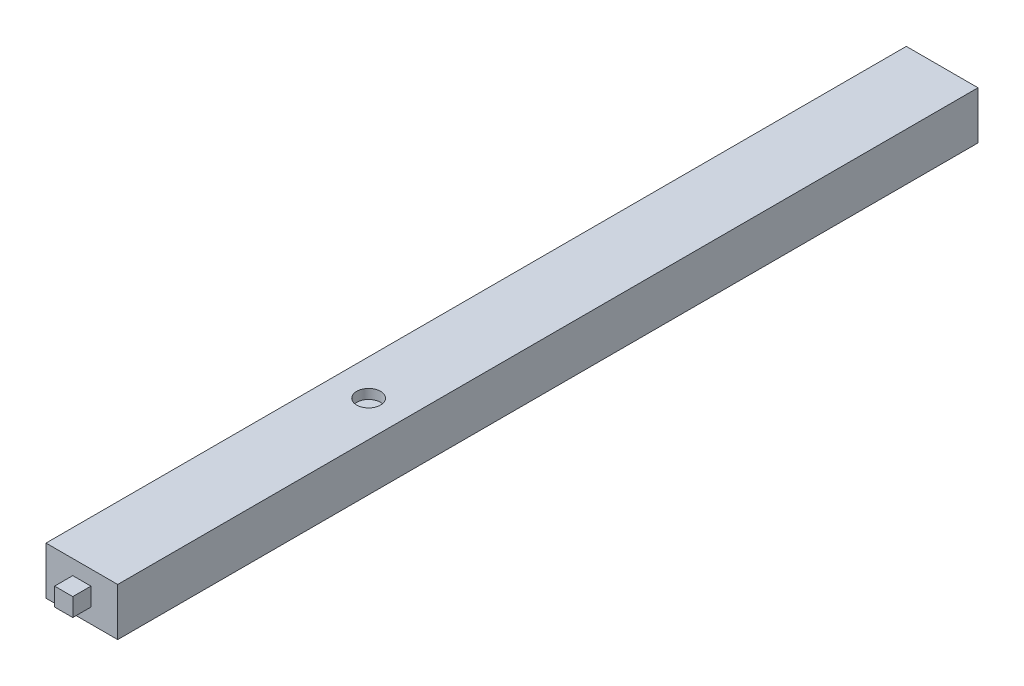
from build123d import *

# Parameters (mm, degrees)
SKETCH1_W           = 15
SKETCH1_H           = 10
BOSS_EXTRUDE1_DEPTH = 180
SKETCH2_W           = 3.8
SKETCH2_H           = 3.8
BOSS_EXTRUDE2_DEPTH = 3.8
SKETCH3_R           = 2.5
CUT_EXTRUDE1_DEPTH  = 2


with BuildPart() as part:
    # Sketch1 → Boss-Extrude1 (new body)
    with BuildSketch(Plane.XY):
        Rectangle(SKETCH1_W, SKETCH1_H)
    extrude(amount=BOSS_EXTRUDE1_DEPTH)

    # Sketch2 → Boss-Extrude2 (add)
    with BuildSketch(Plane.XY.offset(180)):
        Rectangle(SKETCH2_W, SKETCH2_H)
    extrude(amount=BOSS_EXTRUDE2_DEPTH)

    # Sketch3 → Cut-Extrude1 (cut)
    with BuildSketch(Plane(origin=(0, 5, 0), x_dir=(1, 0, 0), z_dir=(0, 1, 0))):
        with Locations((0, -120)):
            Circle(SKETCH3_R)
    extrude(amount=-CUT_EXTRUDE1_DEPTH, mode=Mode.SUBTRACT)


solid = part.part
